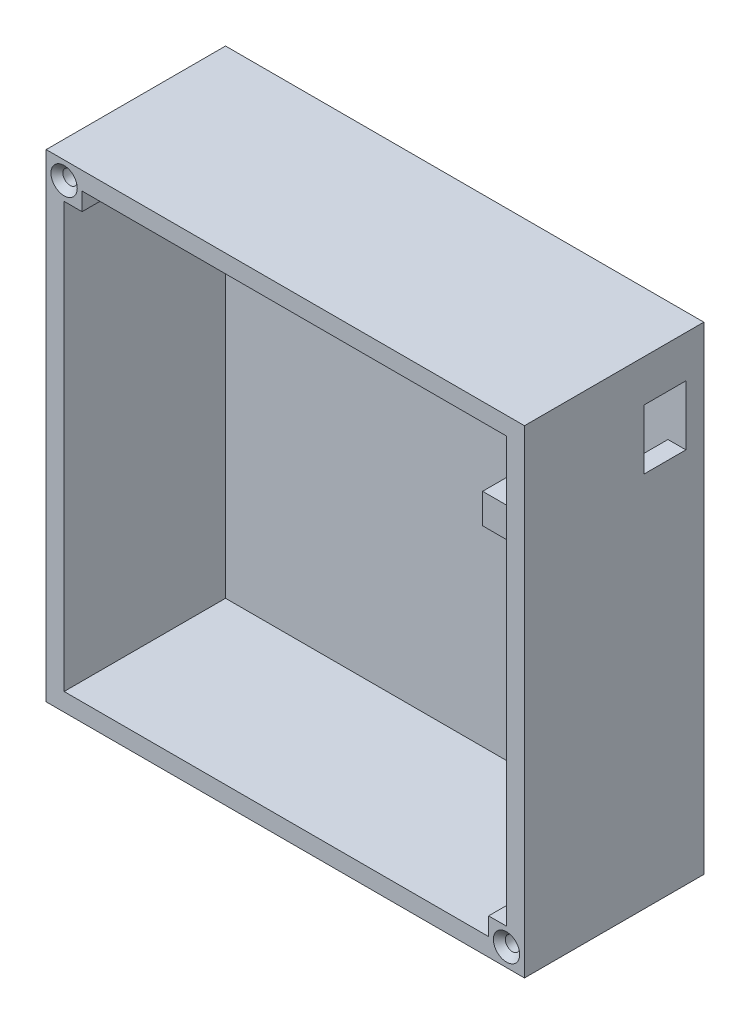
from build123d import *

# Parameters (mm, degrees)
SKETCH1_W                                           = 80
SKETCH1_H                                           = 80
BOSS_EXTRUDE1_DEPTH                                 = 30
SKETCH2_W                                           = 74
SKETCH2_H                                           = 74
CUT_EXTRUDE1_DEPTH                                  = 27
CUT_EXTRUDE2_DEPTH                                  = 3
SKETCH5_W                                           = 3
SKETCH5_H                                           = 3
BOSS_EXTRUDE3_DEPTH                                 = 27
SKETCH6_W                                           = 3
SKETCH6_H                                           = 3
BOSS_EXTRUDE4_DEPTH                                 = 27
CSK_FOR_M2_COUNTERSUNK_FLAT_HEAD_SCREW1_D           = 2.4
CSK_FOR_M2_COUNTERSUNK_FLAT_HEAD_SCREW1_CSINK_D     = 4.4
CSK_FOR_M2_COUNTERSUNK_FLAT_HEAD_SCREW1_CSINK_ANGLE = 90
BOSS_EXTRUDE5_DEPTH                                 = 3
SKETCH10_W                                          = 5
SKETCH10_H                                          = 5
BOSS_EXTRUDE6_DEPTH                                 = 19


with BuildPart() as part:
    # Sketch1 → Boss-Extrude1 (new body)
    with BuildSketch(Plane.XY):
        with Locations((40, 40)):
            Rectangle(SKETCH1_W, SKETCH1_H)
    extrude(amount=BOSS_EXTRUDE1_DEPTH)

    # Sketch2 → Cut-Extrude1 (cut)
    with BuildSketch(Plane.XY.offset(30)):
        with Locations((40, 40)):
            Rectangle(SKETCH2_W, SKETCH2_H)
    extrude(amount=-CUT_EXTRUDE1_DEPTH, mode=Mode.SUBTRACT)

    # Sketch3 → Cut-Extrude2 (cut)
    with BuildSketch(Plane(origin=(80, 0, 0), x_dir=(0, 0, -1), z_dir=(1, 0, 0))):
        Polygon((-3, 68), (-3, 63), (-10, 63), (-10, 68), (-10, 73), (-3, 73), align=None)
    extrude(amount=-CUT_EXTRUDE2_DEPTH, mode=Mode.SUBTRACT)

    # Sketch5 → Boss-Extrude3 (add)
    with BuildSketch(Plane.XY.offset(3)):
        with Locations((4.5, 75.5)):
            Rectangle(SKETCH5_W, SKETCH5_H)
    extrude(amount=BOSS_EXTRUDE3_DEPTH)

    # Sketch6 → Boss-Extrude4 (add)
    with BuildSketch(Plane.XY.offset(3)):
        with Locations((75.5, 4.5)):
            Rectangle(SKETCH6_W, SKETCH6_H)
    extrude(amount=BOSS_EXTRUDE4_DEPTH)

    # CSK for M2 Countersunk Flat Head Screw1 (through all)
    with Locations(Plane.XY.offset(30)):
        with Locations((3, 77), (77, 3)):
            CounterSinkHole(CSK_FOR_M2_COUNTERSUNK_FLAT_HEAD_SCREW1_D / 2, CSK_FOR_M2_COUNTERSUNK_FLAT_HEAD_SCREW1_CSINK_D / 2, counter_sink_angle=CSK_FOR_M2_COUNTERSUNK_FLAT_HEAD_SCREW1_CSINK_ANGLE)

    # Sketch9 → Boss-Extrude5 (add)
    with BuildSketch(Plane.XY.offset(3)):
        Polygon((50, 68), (50, 69), (47.538755388, 69), (47.538755388, 68), (47.538755388, 67), (50, 67), align=None)
    extrude(amount=BOSS_EXTRUDE5_DEPTH)

    # Sketch10 → Boss-Extrude6 (add)
    with BuildSketch(Plane.XY.offset(3)):
        with Locations((67.5, 56.5)):
            Rectangle(SKETCH10_W, SKETCH10_H)
    extrude(amount=BOSS_EXTRUDE6_DEPTH)


solid = part.part
